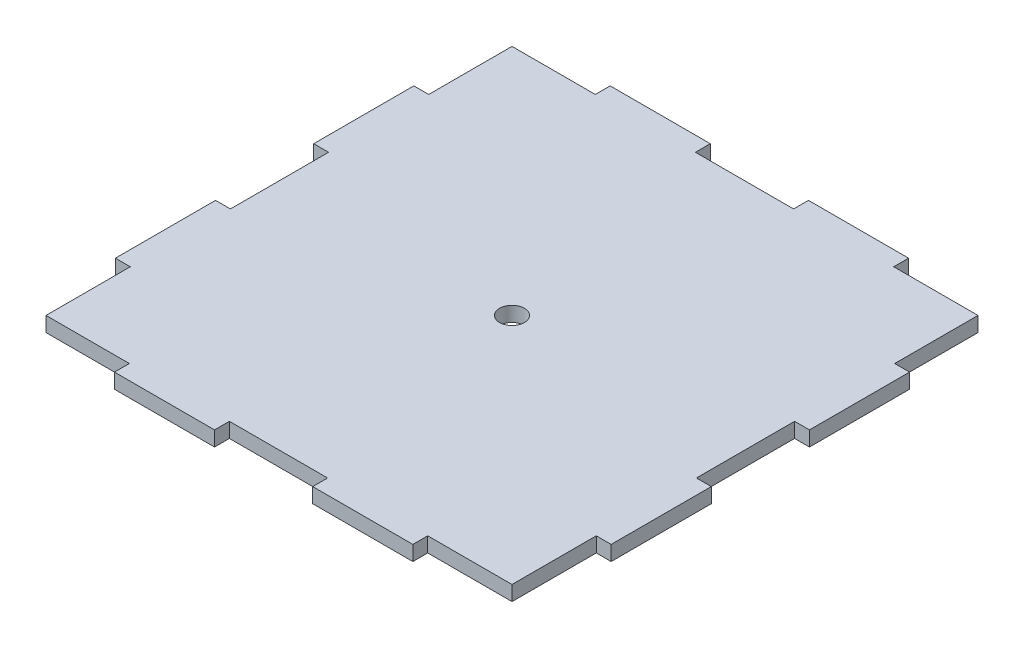
from build123d import *

# Parameters (mm, degrees)
SKETCH1_R           = 2.5
BOSS_EXTRUDE1_DEPTH = 3


with BuildPart() as part:
    # Sketch1 → Boss-Extrude1 (new body)
    with BuildSketch(Plane(origin=(0, 0, 0), x_dir=(1, 0, 0), z_dir=(0, 1, 0))):
        Polygon((59.8, 97), (40, 97), (40, 100), (19.8, 100), (19.8, 97), (3, 97), (3, 80.2), (0, 80.2), (0, 60), (3, 60), (3, 40.2), (0, 40.2), (0, 20), (3, 20), (3, 3), (19.8, 3), (19.8, 0), (40, 0), (40, 3), (59.8, 3), (59.8, 0), (80, 0), (80, 3), (97, 3), (97, 20), (100, 20), (100, 40.2), (97, 40.2), (97, 60), (100, 60), (100, 80.2), (97, 80.2), (97, 97), (80, 97), (80, 100), (59.8, 100), align=None)
        with Locations((50, 50)):
            Circle(SKETCH1_R, mode=Mode.SUBTRACT)
    extrude(amount=BOSS_EXTRUDE1_DEPTH)


solid = part.part
